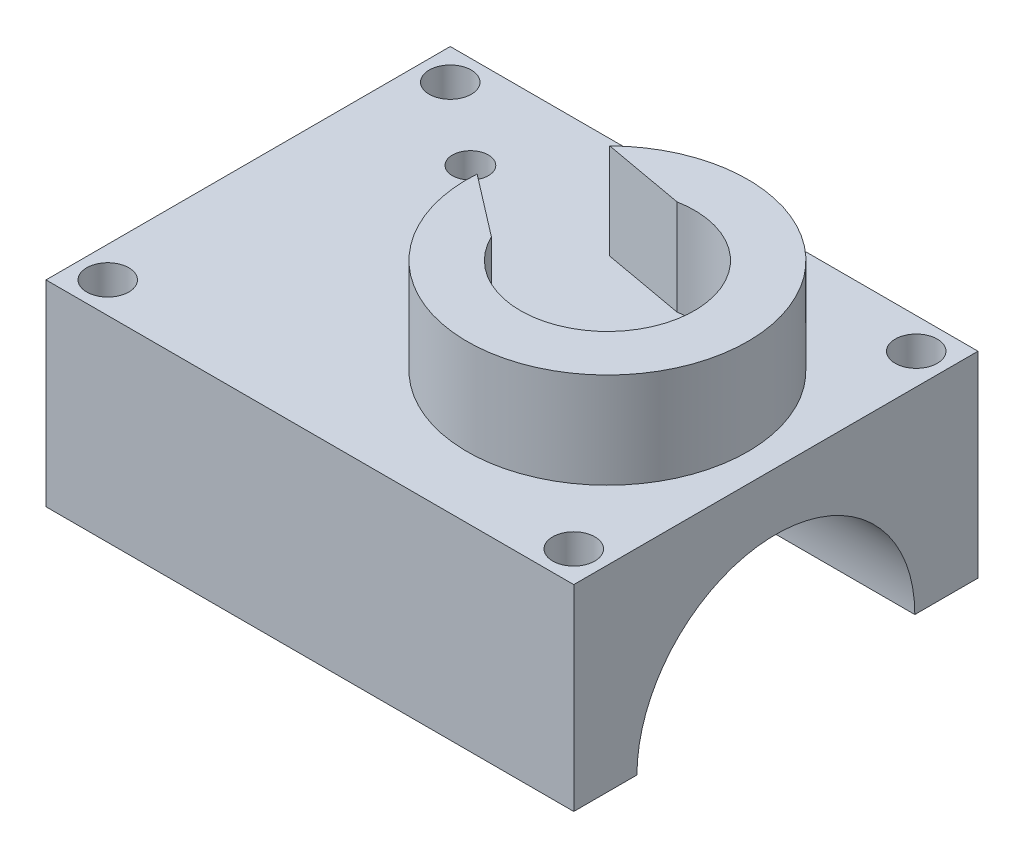
from build123d import *

# Parameters (mm, degrees)
SKETCH1_W           = 60
SKETCH1_H           = 36
BOSS_EXTRUDE1_DEPTH = 35
SKETCH3_R           = 12.375
CUT_EXTRUDE1_DEPTH  = 61
SKETCH5_R           = 1.875
CUT_EXTRUDE2_DEPTH  = 40
CUT_EXTRUDE3_START  = 30
SKETCH7_W           = 36
SKETCH7_H           = 17.5
CUT_EXTRUDE3_DEPTH  = 61
SKETCH19_R          = 2.885
CUT_EXTRUDE13_DEPTH = 14
SKETCH20_R          = 1.6
CUT_EXTRUDE14_DEPTH = 13
SKETCH21_R          = 1.6
CUT_EXTRUDE15_DEPTH = 18.5000001
SKETCH22_W          = 5.7
SKETCH22_H          = 6.805143355
CUT_EXTRUDE16_DEPTH = 12
SKETCH23_R          = 12.5
SKETCH23_R_2        = 7.75
BOSS_EXTRUDE2_DEPTH = 8.5
CUT_EXTRUDE17_DEPTH = 8.5
SKETCH25_W          = 40.384912637
SKETCH25_H          = 20.483413903
CUT_EXTRUDE18_DEPTH = 13


with BuildPart() as part:
    # Sketch1 → Boss-Extrude1 (new body)
    with BuildSketch(Plane(origin=(0, 0, 0), x_dir=(1, 0, 0), z_dir=(0, 1, 0))):
        Rectangle(SKETCH1_W, SKETCH1_H)
    extrude(amount=BOSS_EXTRUDE1_DEPTH)

    # Sketch3 → Cut-Extrude1 (cut, through all)
    with BuildSketch(Plane(origin=(30, 0, 0), x_dir=(0, 0, -1), z_dir=(1, 0, 0))):
        with Locations((0, 17.5)):
            Circle(SKETCH3_R)
    extrude(amount=-CUT_EXTRUDE1_DEPTH, mode=Mode.SUBTRACT)

    # Sketch5 → Cut-Extrude2 (cut)
    with BuildSketch(Plane(origin=(0, 35, 0), x_dir=(1, 0, 0), z_dir=(0, 1, 0))):
        with Locations((27.25, -15.25)):
            Circle(SKETCH5_R)
        with Locations((27.25, 15.25)):
            Circle(SKETCH5_R)
        with Locations((-14.25, -15.25)):
            Circle(SKETCH5_R)
        with Locations((-14.25, 15.25)):
            Circle(SKETCH5_R)
    extrude(amount=-CUT_EXTRUDE2_DEPTH, mode=Mode.SUBTRACT)

    # Sketch7 → Cut-Extrude3 (cut, through all)
    with BuildSketch(Plane(origin=(0, 0, 0), x_dir=(0, 0, -1), z_dir=(1, 0, 0)).offset(CUT_EXTRUDE3_START)):
        with Locations((0, 8.75)):
            Rectangle(SKETCH7_W, SKETCH7_H)
    extrude(amount=-CUT_EXTRUDE3_DEPTH, mode=Mode.SUBTRACT)

    # Sketch19 → Cut-Extrude13 (cut)
    with BuildSketch(Plane.XZ.offset(-17.5)):
        with Locations((15, 0)):
            Circle(SKETCH19_R)
    extrude(amount=-CUT_EXTRUDE13_DEPTH, mode=Mode.SUBTRACT)

    # Sketch20 → Cut-Extrude14 (cut)
    with BuildSketch(Plane.XZ.offset(-31.5)):
        with Locations((15, 0)):
            Circle(SKETCH20_R)
    extrude(amount=-CUT_EXTRUDE14_DEPTH, mode=Mode.SUBTRACT)

    # Sketch21 → Cut-Extrude15 (cut, through all)
    with BuildSketch(Plane(origin=(0, 35, 0), x_dir=(1, 0, 0), z_dir=(0, 1, 0))):
        with Locations((-6.937800687, 9.733082811)):
            Circle(SKETCH21_R)
    extrude(amount=-CUT_EXTRUDE15_DEPTH, mode=Mode.SUBTRACT)

    # Sketch22 → Cut-Extrude16 (cut)
    with BuildSketch(Plane.XZ.offset(-17.5)):
        with Locations((-6.954606202, -8.972428323)):
            Rectangle(SKETCH22_W, SKETCH22_H)
    extrude(amount=-CUT_EXTRUDE16_DEPTH, mode=Mode.SUBTRACT)

    # Sketch23 → Boss-Extrude2 (add)
    with BuildSketch(Plane(origin=(0, 35, 0), x_dir=(1, 0, 0), z_dir=(0, 1, 0))):
        with Locations((15, 0)):
            Circle(SKETCH23_R)
        with Locations((15, 0)):
            Circle(SKETCH23_R_2, mode=Mode.SUBTRACT)
    extrude(amount=BOSS_EXTRUDE2_DEPTH)

    # Sketch24 → Cut-Extrude17 (cut)
    with BuildSketch(Plane(origin=(0, 43.5, 0), x_dir=(1, 0, 0), z_dir=(0, 1, 0))):
        Polygon((-6.937800687, 8.133082811), (13.574185936, -7.617713191), (13.574185936, 7.617713191), (-6.317460524, 11.207931305), align=None)
    extrude(amount=-CUT_EXTRUDE17_DEPTH, mode=Mode.SUBTRACT)

    # Sketch25 → Cut-Extrude18 (cut)
    with BuildSketch(Plane.ZY.offset(30)):
        with Locations((-0.290957584, 25.898615679)):
            Rectangle(SKETCH25_W, SKETCH25_H)
    extrude(amount=-CUT_EXTRUDE18_DEPTH, mode=Mode.SUBTRACT)


solid = part.part
